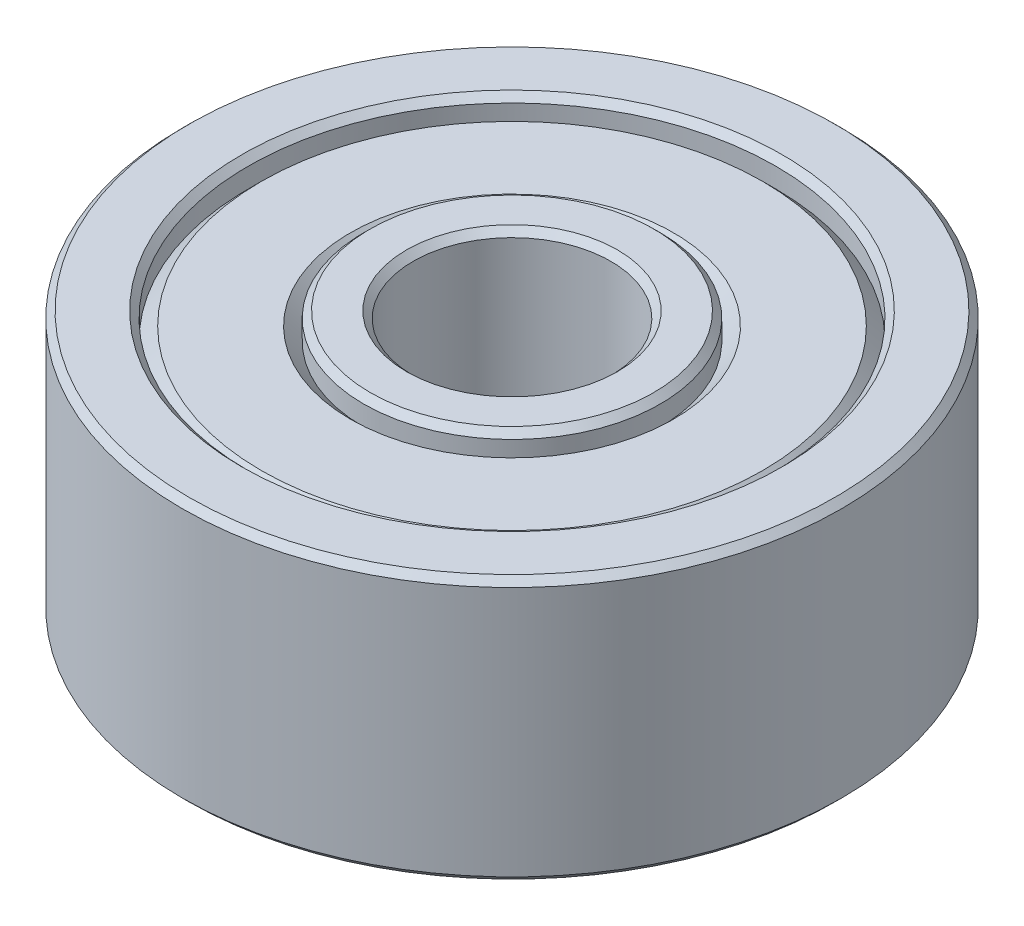
from build123d import *

# Parameters (mm, degrees)
SKETCH1_W     = 3.5
SKETCH1_H     = 4
CHAMFER1_SIZE = 0.1


with BuildPart() as part:
    # Sketch1 → Revolve1 (revolve)
    with BuildSketch(Plane(origin=(0, 0, 0), x_dir=(0, 0, -1), z_dir=(1, 0, 0))):
        with Locations((3.25, 0)):
            Rectangle(SKETCH1_W, SKETCH1_H)
    revolve(axis=Axis((0, 2, 0), (0, -1, 0)))

    # Sketch3 → Cut-Revolve2 (revolve, cut)
    with BuildSketch(Plane(origin=(0, 0, 0), x_dir=(0, 0, -1), z_dir=(1, 0, 0))):
        Polygon((3.8, 1.8), (4, 1.6), (4, 2), (2.25, 2), (2.25, 1.6), (2.45, 1.8), align=None)
    cut_revolve2 = revolve(axis=Axis((0, 2, 0), (0, -1, 0)), mode=Mode.SUBTRACT)

    # Mirror1: Cut-Revolve2 across plane
    add(cut_revolve2.mirror(Plane.ZX), mode=Mode.SUBTRACT)

    # Chamfer1
    chamfer1_edges = [part.edges().sort_by_distance(p)[0] for p in [
        (0, 2, 4),
        (0, 2, 2.25),
        (0, -2, 4),
        (0, -2, 2.25),
        (0, 2, 5),
        (0, -2, 5),
        (0, -2, 1.5),
        (0, 2, 1.5),
    ]]
    chamfer(chamfer1_edges, length=CHAMFER1_SIZE)


solid = part.part
